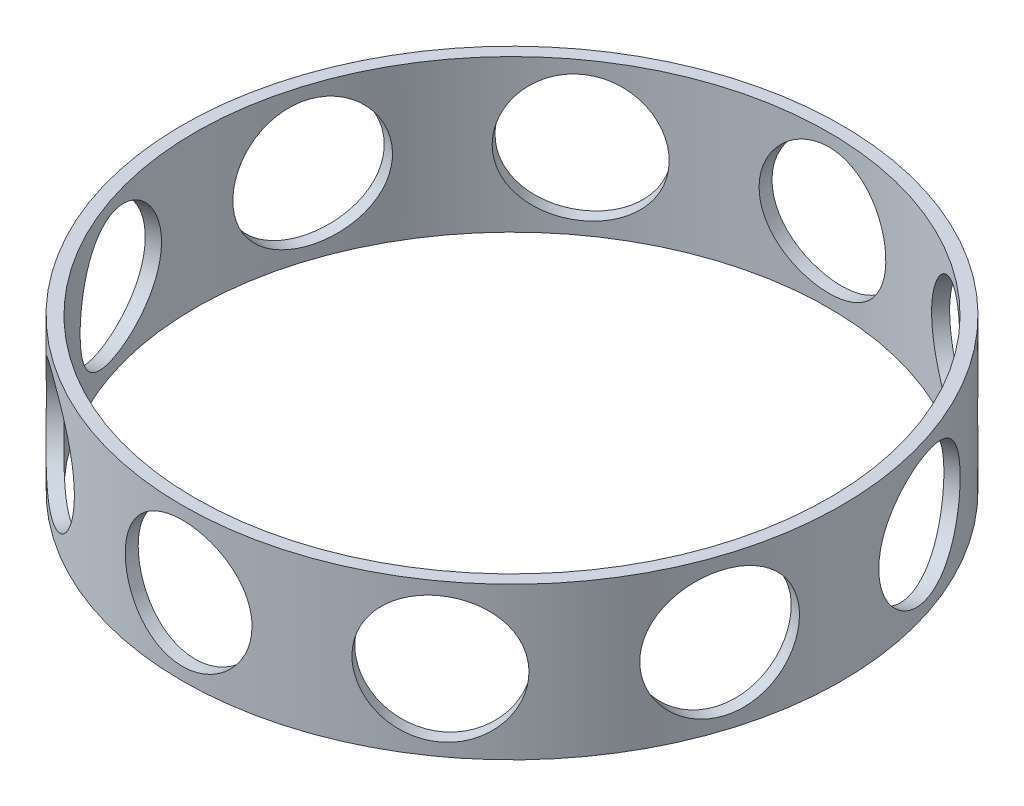
from build123d import *

# Parameters (mm, degrees)
SKETCH1_R           = 13
SKETCH1_R_2         = 12.5
BOSS_EXTRUDE2_DEPTH = 6
SKETCH5_R           = 2.5
CUT_EXTRUDE1_DEPTH  = 14
CIRPATTERN1_COUNT   = 5


with BuildPart() as part:
    # Sketch1 → Boss-Extrude2 (new body)
    with BuildSketch(Plane(origin=(0, 0, 0), x_dir=(1, 0, 0), z_dir=(0, 1, 0))):
        Circle(SKETCH1_R)
        Circle(SKETCH1_R_2, mode=Mode.SUBTRACT)
    extrude(amount=BOSS_EXTRUDE2_DEPTH)

    # Sketch5 → Cut-Extrude1 (cut, symmetric)
    with BuildSketch(Plane.XY):
        with Locations((0, 3)):
            Circle(SKETCH5_R)
    cut_extrude1 = extrude(amount=CUT_EXTRUDE1_DEPTH, both=True, mode=Mode.SUBTRACT)

    # CirPattern1: Cut-Extrude1 ×5 about axis
    cirpattern1_axis = Axis((0, 6, 0), (0, -1, 0))
    for i in range(1, CIRPATTERN1_COUNT):
        add(cut_extrude1.rotate(cirpattern1_axis, i * 360 / CIRPATTERN1_COUNT), mode=Mode.SUBTRACT)


solid = part.part
